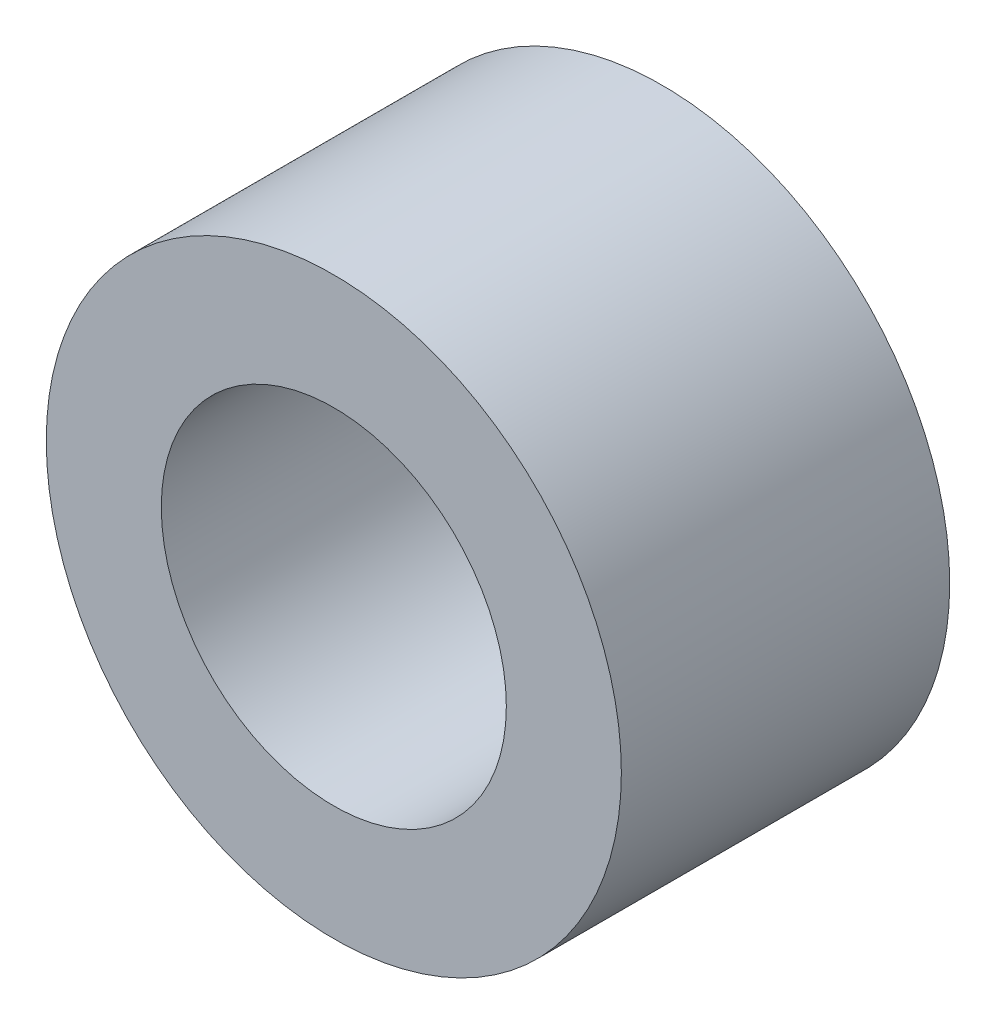
from build123d import *

# Parameters (mm, degrees)
SKETCH1_R           = 12.7
SKETCH1_R_2         = 7.62
BOSS_EXTRUDE1_DEPTH = 14.5034


with BuildPart() as part:
    # Sketch1 → Boss-Extrude1 (new body)
    with BuildSketch(Plane.XY):
        Circle(SKETCH1_R)
        Circle(SKETCH1_R_2, mode=Mode.SUBTRACT)
    extrude(amount=BOSS_EXTRUDE1_DEPTH)


solid = part.part
